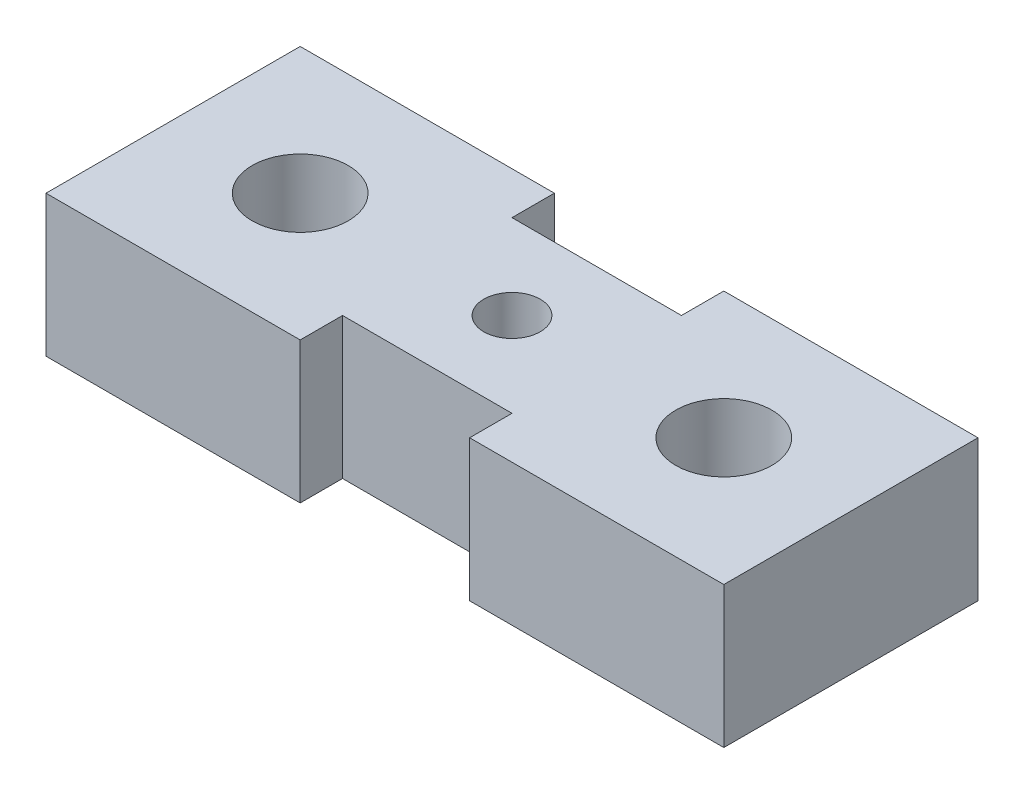
from build123d import *

# Parameters (mm, degrees)
SKETCH3_W           = 24
SKETCH3_H           = 9
BOSS_EXTRUDE2_DEPTH = 5
SKETCH4_R           = 1.7
SKETCH4_R_2         = 1
SKETCH4_W           = 6
SKETCH4_H           = 1.5
CUT_EXTRUDE1_DEPTH  = 5


with BuildPart() as part:
    # Sketch3 → Boss-Extrude2 (new body)
    with BuildSketch(Plane(origin=(0, 0, 0), x_dir=(1, 0, 0), z_dir=(0, 1, 0))):
        with Locations((-102.694405771, -24.955608755)):
            Rectangle(SKETCH3_W, SKETCH3_H)
    extrude(amount=BOSS_EXTRUDE2_DEPTH)

    # Sketch4 → Cut-Extrude1 (cut)
    with BuildSketch(Plane(origin=(0, 5, 0), x_dir=(1, 0, 0), z_dir=(0, 1, 0))):
        with Locations((-110.194405771, -24.955608755)):
            Circle(SKETCH4_R)
        with Locations((-95.194405771, -24.955608755)):
            Circle(SKETCH4_R)
        with Locations((-102.694405771, -24.955608755)):
            Circle(SKETCH4_R_2)
        with Locations((-102.694405771, -28.705608755)):
            Rectangle(SKETCH4_W, SKETCH4_H)
        with Locations((-102.694405771, -21.205608755)):
            Rectangle(SKETCH4_W, SKETCH4_H)
    extrude(amount=-CUT_EXTRUDE1_DEPTH, mode=Mode.SUBTRACT)


solid = part.part
